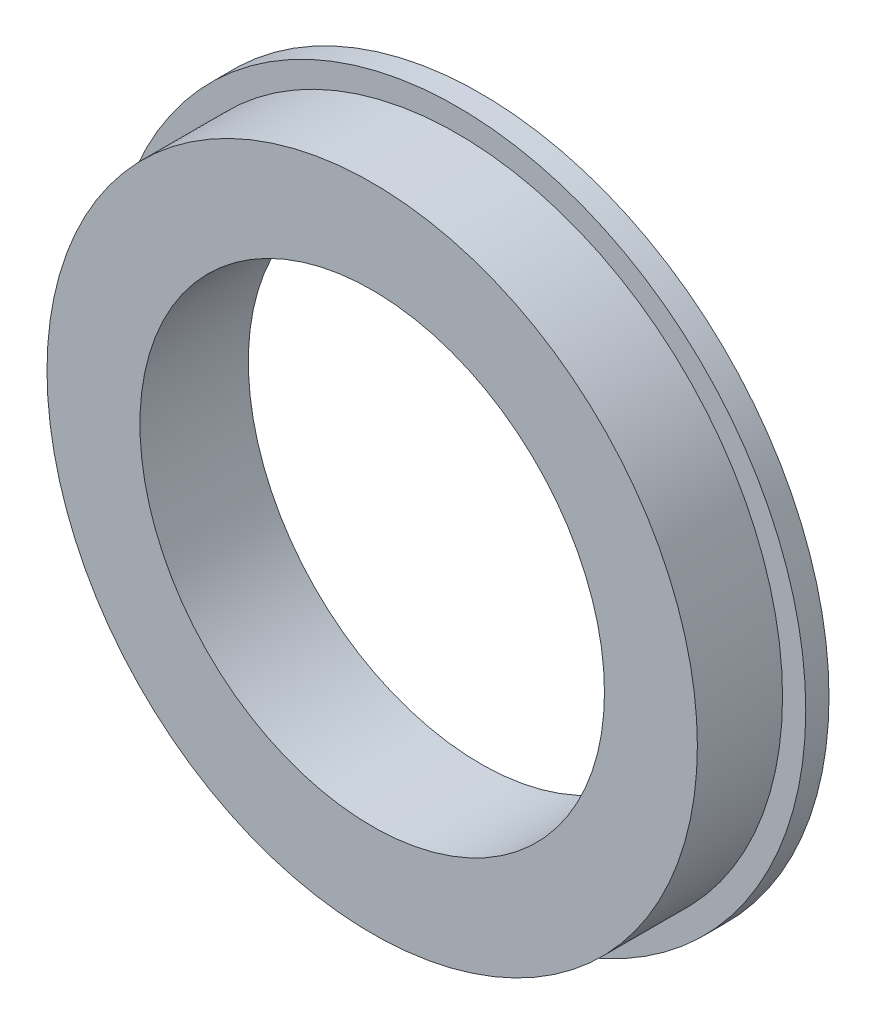
from build123d import *

# Parameters (mm, degrees)
SKETCH_1_R      = 21
SKETCH_1_R_2    = 15
EXTRUDE_1_DEPTH = 7
SKETCH_2_R      = 22.5
SKETCH_2_R_2    = 21
EXTRUDE_2_DEPTH = 1.5


with BuildPart() as part:
    # 草图1 → 凸台-拉伸1 (new body)
    with BuildSketch(Plane.XY):
        Circle(SKETCH_1_R)
        Circle(SKETCH_1_R_2, mode=Mode.SUBTRACT)
    extrude(amount=EXTRUDE_1_DEPTH)

    # 草图2 → 凸台-拉伸2 (add)
    with BuildSketch(Plane.XY):
        Circle(SKETCH_2_R)
        Circle(SKETCH_2_R_2, mode=Mode.SUBTRACT)
    extrude(amount=EXTRUDE_2_DEPTH)


solid = part.part
